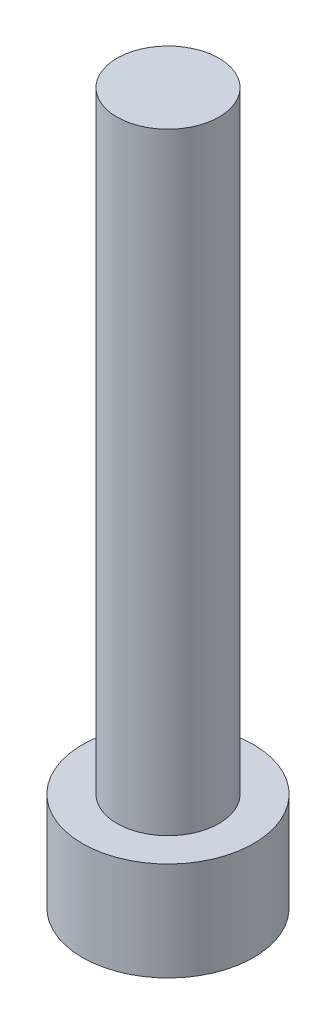
from build123d import *

# Parameters (mm, degrees)
SKETCH_1_R          = 4.2
EXTRUDE_1_DEPTH     = 4.84
SKETCH_2_R          = 2.5
EXTRUDE_2_DEPTH     = 30
CUT_EXTRUDE_1_DEPTH = 3.4


with BuildPart() as part:
    # 草图1 → 凸台-拉伸1 (new body)
    with BuildSketch(Plane(origin=(0, 0, 0), x_dir=(1, 0, 0), z_dir=(0, 1, 0))):
        Circle(SKETCH_1_R)
    extrude(amount=EXTRUDE_1_DEPTH)

    # 草图2 → 凸台-拉伸2 (add)
    with BuildSketch(Plane(origin=(0, 4.84, 0), x_dir=(1, 0, 0), z_dir=(0, 1, 0))):
        Circle(SKETCH_2_R)
    extrude(amount=EXTRUDE_2_DEPTH)

    # 草图3 → 切除-拉伸1 (cut)
    with BuildSketch(Plane.XZ):
        Polygon((2.3, 0), (1.15, 1.991858429), (-1.15, 1.991858429), (-2.3, 0), (-1.15, -1.991858429), (1.15, -1.991858429), align=None)
    extrude(amount=-CUT_EXTRUDE_1_DEPTH, mode=Mode.SUBTRACT)


solid = part.part
